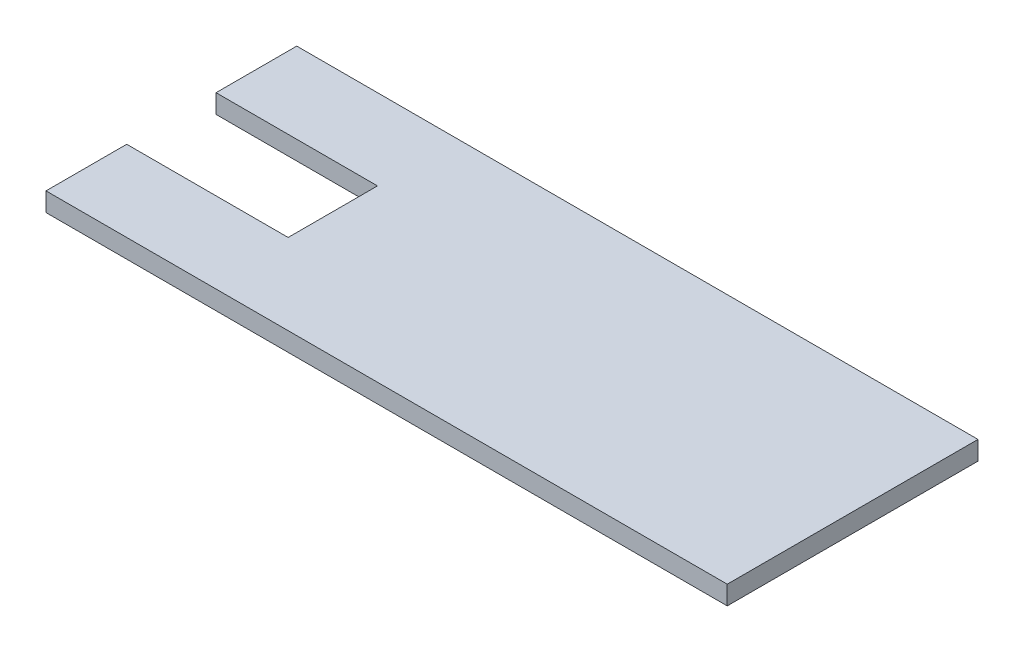
from build123d import *

# Parameters (mm, degrees)
SKETCH2_W           = 126.6
SKETCH2_H           = 46.6
BOSS_EXTRUDE1_DEPTH = 3.5
SKETCH3_W           = 30
SKETCH3_H           = 16.6
CUT_EXTRUDE1_DEPTH  = 3.5


with BuildPart() as part:
    # Sketch2 → Boss-Extrude1 (new body)
    with BuildSketch(Plane(origin=(0, 0, 0), x_dir=(1, 0, 0), z_dir=(0, 1, 0))):
        Rectangle(SKETCH2_W, SKETCH2_H)
    extrude(amount=BOSS_EXTRUDE1_DEPTH)

    # Sketch3 → Cut-Extrude1 (cut)
    with BuildSketch(Plane(origin=(0, 3.5, 0), x_dir=(1, 0, 0), z_dir=(0, 1, 0))):
        with Locations((-48.3, 0)):
            Rectangle(SKETCH3_W, SKETCH3_H)
    extrude(amount=-CUT_EXTRUDE1_DEPTH, mode=Mode.SUBTRACT)


solid = part.part
